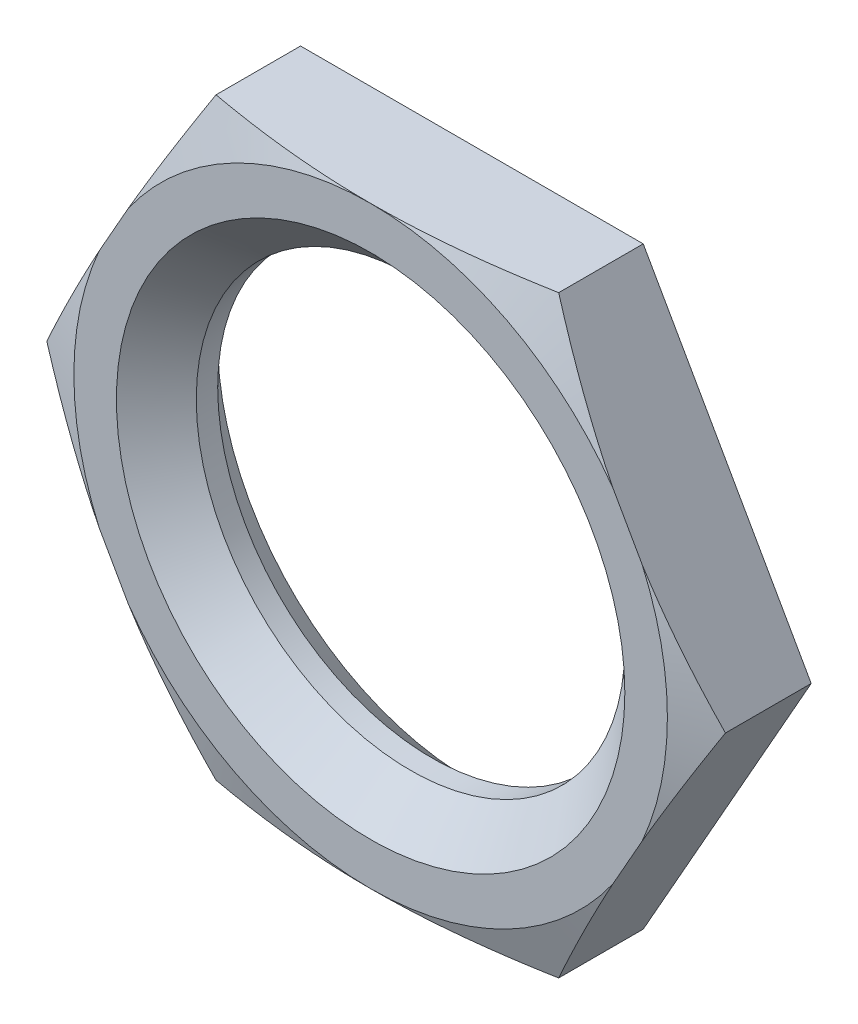
from build123d import *

# Parameters (mm, degrees)
SKETCH2_W               = 27.9908
SKETCH2_H               = 27.9908
CUT_EXTRUDE1_DEPTH      = 2.3876
CUT_EXTRUDE1_DEPTH_BACK = 2.3876


with BuildPart() as part:
    # Sketch1 → Revolve1 (revolve)
    with BuildSketch(Plane(origin=(0, 0, 0), x_dir=(0, 0, -1), z_dir=(1, 0, 0))):
        Polygon((-1.1938, 0), (-1.1938, 6.9977), (-0.684409098, 8.39724), (1.1938, 8.39724), (1.1938, 0), align=None)
    revolve(axis=Axis((0, 0, -1.1938), (0, 0, 1)))

    # Sketch2 → Cut-Extrude1 (cut, two sides)
    with BuildSketch(Plane.XY) as cut_extrude1_sk:
        Rectangle(SKETCH2_W, SKETCH2_H)
        Polygon((-8.001, 0), (-4.040123979, -6.9977), (4.040123979, -6.9977), (8.001, 0), (4.040123979, 6.9977), (-4.040123979, 6.9977), align=None, mode=Mode.SUBTRACT)
    extrude(amount=CUT_EXTRUDE1_DEPTH, mode=Mode.SUBTRACT)
    extrude(cut_extrude1_sk.sketch, amount=-CUT_EXTRUDE1_DEPTH_BACK, mode=Mode.SUBTRACT)

    # Sketch3 → Cut-Revolve1 (revolve, cut)
    with BuildSketch(Plane(origin=(0, 0, 0), x_dir=(0, 0, -1), z_dir=(1, 0, 0))):
        Polygon((-1.1938, 0), (-1.1938, 5.9944), (-0.2524, 5.053), (0.2524, 5.053), (1.1938, 5.9944), (1.1938, 0), align=None)
    revolve(axis=Axis((0, 0, -1.1938), (0, 0, 1)), mode=Mode.SUBTRACT)


solid = part.part
